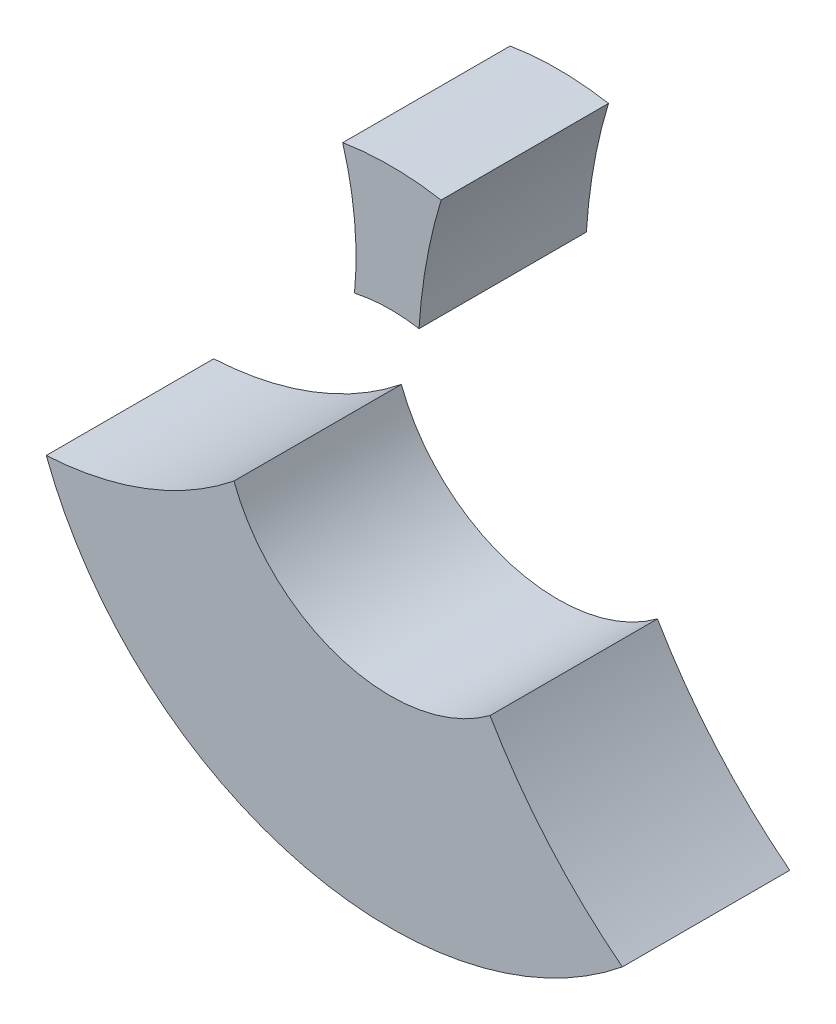
from build123d import *

# Parameters (mm, degrees)
SKETCH1_R           = 13.2
SKETCH1_R_2         = 6
BOSS_EXTRUDE1_DEPTH = 6
CUT_EXTRUDE1_DEPTH  = 7


with BuildPart() as part:
    # Sketch1 → Boss-Extrude1 (new body)
    with BuildSketch(Plane.XY):
        Circle(SKETCH1_R)
        Circle(SKETCH1_R_2, mode=Mode.SUBTRACT)
    extrude(amount=BOSS_EXTRUDE1_DEPTH)

    # Sketch2 → Cut-Extrude1 (cut, through all)
    with BuildSketch(Plane.XY.offset(6)):
        with BuildLine():
            ThreePointArc((-2.819851171, 12.895287487), (0, 13.2), (2.819851171, 12.895287487))
            ThreePointArc((2.819851171, 12.895287487), (37.775013156, -2.116749246), (1.816638208, 10.301779947))
            ThreePointArc((1.816638208, 10.301779947), (0.05404213, 10.46058908), (-1.710100717, 10.32))
            ThreePointArc((-1.710100717, 10.32), (-23.713414375, 2.365019601), (-2.819851171, 12.895287487))
        make_face()
    extrude(amount=-CUT_EXTRUDE1_DEPTH, mode=Mode.SUBTRACT)


solid = part.part
